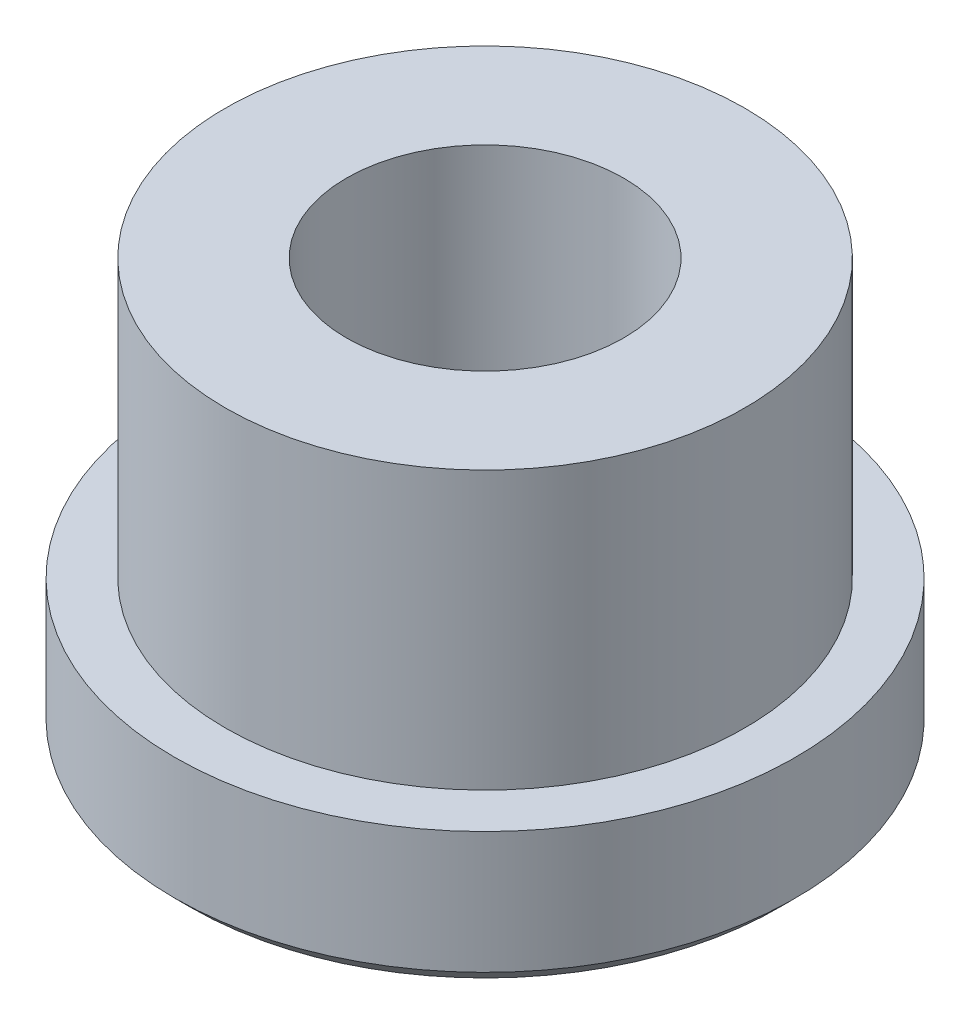
from build123d import *

# Parameters (mm, degrees)
CHAMFER1_SIZE = 0.762


with BuildPart() as part:
    # Sketch2 → Revolve1 (revolve)
    with BuildSketch(Plane.XY):
        Polygon((14.224, 0), (14.224, 6.35), (11.8999, 6.35), (11.8999, 19.05), (6.35, 19.05), (6.35, 0), align=None)
    revolve(axis=Axis((0, 0, 0), (0, -1, 0)))

    # Chamfer1
    chamfer1_edges = [part.edges().sort_by_distance(p)[0] for p in [
        (-14.224, 0, 0),
    ]]
    chamfer(chamfer1_edges, length=CHAMFER1_SIZE)


solid = part.part
